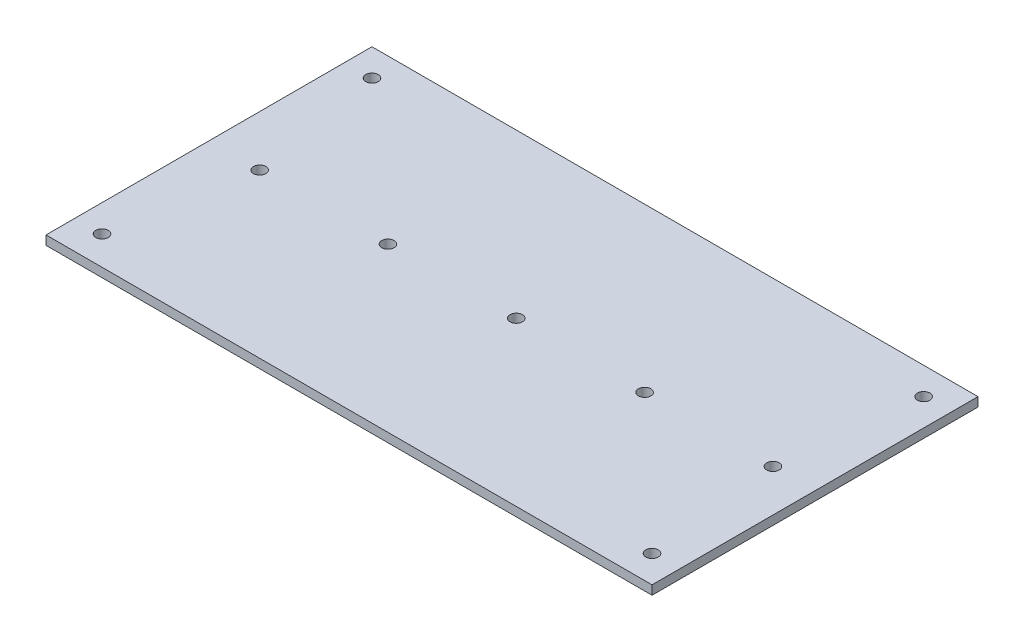
from build123d import *

# Parameters (mm, degrees)
SKETCH1_W                             = 425
SKETCH1_H                             = 228.6
BASE_DEPTH                            = 6.35
HOLE_FOR_1_4_BLIND_FASTENERS_B_BS_1_D = 8.7376
HOLE_FOR_1_4_BLIND_FASTENERS_B_BS_2_D = 8.7376


with BuildPart() as part:
    # Sketch1 → Base (new body)
    with BuildSketch(Plane(origin=(0, 0, 0), x_dir=(1, 0, 0), z_dir=(0, 1, 0))):
        with Locations((212.5, -114.3)):
            Rectangle(SKETCH1_W, SKETCH1_H)
    extrude(amount=-BASE_DEPTH)

    # Hole for 1/4 Blind Fasteners (B,BS)1 (through all)
    with Locations(Plane(origin=(0, 0, 0), x_dir=(1, 0, 0), z_dir=(0, 1, 0))):
        with Locations((35.5, -114.3), (125.49982, -114.3), (215.49964, -114.3), (305.49946, -114.3), (395.49928, -114.3)):
            Hole(HOLE_FOR_1_4_BLIND_FASTENERS_B_BS_1_D / 2)

    # Hole for 1/4 Blind Fasteners (B,BS)2 (through all)
    with Locations(Plane(origin=(0, 0, 0), x_dir=(1, 0, 0), z_dir=(0, 1, 0))):
        with Locations((19.05, -19.05), (19.03407818, -208.365498456), (405.95, -19.05), (405.95, -209.55)):
            Hole(HOLE_FOR_1_4_BLIND_FASTENERS_B_BS_2_D / 2)


solid = part.part
